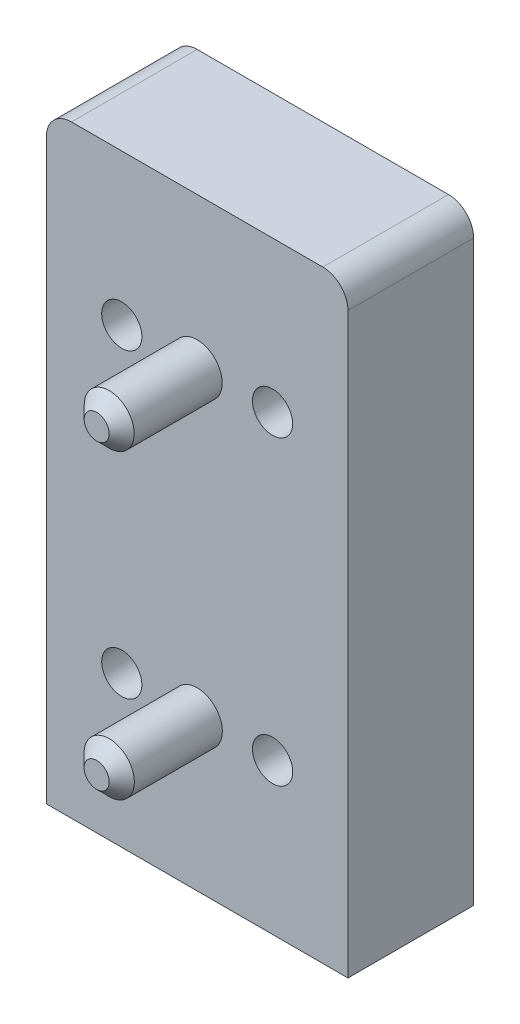
from build123d import *

# Parameters (mm, degrees)
BOSS_EXTRUDE1_DEPTH         = 10
SKETCH2_R                   = 1
CUT_EXTRUDE1_DEPTH          = 0.6
SKETCH3_R                   = 1.99
SKETCH3_R_2                 = 2
BOSS_EXTRUDE3_DEPTH         = 8
CHAMFER3_SIZE               = 1
HOLE_WIZARD_M31_D           = 3.2
HOLE_WIZARD_M31_CSINK_D     = 6.3
HOLE_WIZARD_M31_CSINK_ANGLE = 90
M3X0_51_D                   = 2.5
M3X0_51_DEPTH               = 6.5
M3X0_51_TIP                 = 0.751075774


with BuildPart() as part:
    # Sketch1 → Boss-Extrude1 (new body)
    with BuildSketch(Plane.XY):
        with BuildLine():
            Line((-12, -36), (12, -36))
            Line((12, -36), (12, 10))
            ThreePointArc((12, 10), (11.414213562, 11.414213562), (10, 12))
            Line((10, 12), (-10, 12))
            ThreePointArc((-10, 12), (-11.414213562, 11.414213562), (-12, 10))
            Line((-12, 10), (-12, -36))
        make_face()
    extrude(amount=BOSS_EXTRUDE1_DEPTH)

    # Sketch2 → Cut-Extrude1 (cut)
    with BuildSketch(Plane(origin=(0, 0, 0), x_dir=(-1, 0, 0), z_dir=(0, 0, -1))):
        with Locations((4, -8)):
            Circle(SKETCH2_R)
        with Locations((-0.116, -14.973)):
            Circle(SKETCH2_R)
        with BuildLine():
            Line((-1, -1.5), (1, -1.5))
            ThreePointArc((1, -1.5), (1.853553391, -1.853553391), (1.5, -1))
            Line((1.5, -1), (1.5, 1))
            ThreePointArc((1.5, 1), (1.853553391, 1.853553391), (1, 1.5))
            Line((1, 1.5), (-1, 1.5))
            ThreePointArc((-1, 1.5), (-1.853553391, 1.853553391), (-1.5, 1))
            Line((-1.5, 1), (-1.5, -1))
            ThreePointArc((-1.5, -1), (-1.853553391, -1.853553391), (-1, -1.5))
        make_face()
        with BuildLine():
            Line((-1.76, -26.26), (1.76, -26.26))
            ThreePointArc((1.76, -26.26), (2.613553391, -26.613553391), (2.26, -25.76))
            Line((2.26, -25.76), (2.26, -22.24))
            ThreePointArc((2.26, -22.24), (2.613553391, -21.386446609), (1.76, -21.74))
            Line((1.76, -21.74), (-1.76, -21.74))
            ThreePointArc((-1.76, -21.74), (-2.613553391, -21.386446609), (-2.26, -22.24))
            Line((-2.26, -22.24), (-2.26, -25.76))
            ThreePointArc((-2.26, -25.76), (-2.613553391, -26.613553391), (-1.76, -26.26))
        make_face()
    extrude(amount=-CUT_EXTRUDE1_DEPTH, mode=Mode.SUBTRACT)

    # Sketch3 → Boss-Extrude3 (add)
    with BuildSketch(Plane.XY.offset(10)):
        Circle(SKETCH3_R)
        with Locations((0, -24)):
            Circle(SKETCH3_R_2)
    extrude(amount=BOSS_EXTRUDE3_DEPTH)

    # Chamfer3
    chamfer3_edges = [part.edges().sort_by_distance(p)[0] for p in [
        (-1.99, 0, 18),
        (-2, -24, 18),
    ]]
    chamfer(chamfer3_edges, length=CHAMFER3_SIZE)

    # Зенковка для  винта с полупотайной головкой M31 (through all)
    with Locations(Plane(origin=(0, 0, 0), x_dir=(-1, 0, 0), z_dir=(0, 0, -1))):
        with Locations((6, 0), (-6, 0), (-6, -24), (6, -24)):
            CounterSinkHole(HOLE_WIZARD_M31_D / 2, HOLE_WIZARD_M31_CSINK_D / 2, counter_sink_angle=HOLE_WIZARD_M31_CSINK_ANGLE)

    # Отверстие обработанное метчиком M3x0.51
    with Locations(Plane(origin=(0, 0, 0), x_dir=(-1, 0, 0), z_dir=(0, 0, -1))):
        with Locations((-6.5, -8), (-6.5, 9), (7.5, 9), (7.5, -8), (6.884, -14.975), (6.884, -31.973), (-7.116, -14.973), (-7.116, -31.973)):
            Hole(M3X0_51_D / 2, depth=M3X0_51_DEPTH)
            with Locations((0, 0, -(M3X0_51_DEPTH + M3X0_51_TIP / 2))):  # 118° drill point
                Cone(0, M3X0_51_D / 2, M3X0_51_TIP, mode=Mode.SUBTRACT)


solid = part.part
